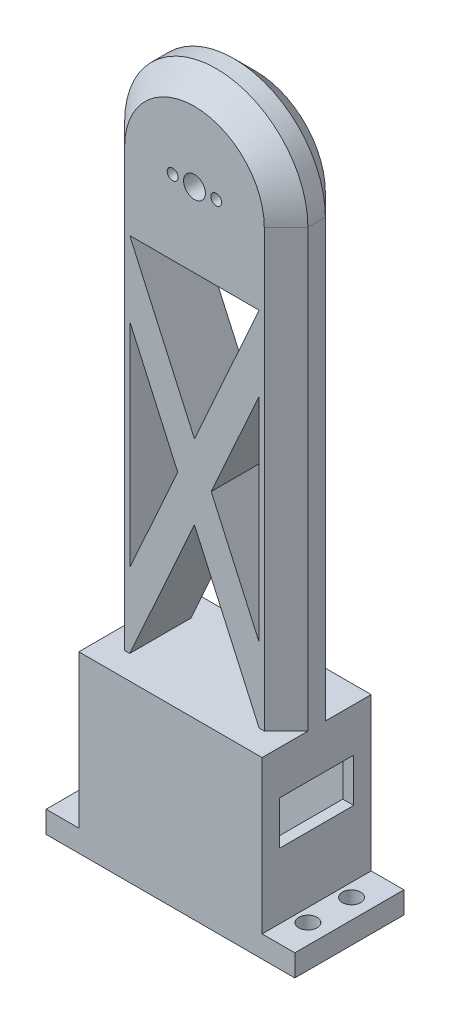
from build123d import *

# Parameters (mm, degrees)
BOSS_EXTRUDE1_DEPTH = 7
SKETCH2_W           = 42
SKETCH2_H           = 25
BOSS_EXTRUDE2_DEPTH = 40
SHELL1_T            = -2.5
CUT_EXTRUDE5_REACH  = 144.903
SKETCH8_R           = 1.25
SKETCH8_R_2         = 2.5
SKETCH9_W           = 10
SKETCH9_H           = 25
BOSS_EXTRUDE3_DEPTH = 5
CUT_EXTRUDE6_REACH  = 151.018
SKETCH10_W          = 17
SKETCH10_H          = 10
CUT_EXTRUDE8_REACH  = 146.196
CUT_EXTRUDE9_REACH  = 165.98
SKETCH13_R          = 2.1
CHAMFER1_SIZE       = 5


with BuildPart() as part:
    # Sketch1 → Boss-Extrude1 (new, symmetric)
    with BuildSketch(Plane.XY):
        with BuildLine():
            Line((-21, 0), (-21, -100))
            Line((-21, -100), (21, -100))
            Line((21, -100), (21, 0))
            ThreePointArc((21, 0), (0, 21), (-21, 0))
        make_face()
    extrude(amount=BOSS_EXTRUDE1_DEPTH, both=True)


with BuildPart() as body_2:
    # Sketch2 → Boss-Extrude2 (new body)
    with BuildSketch(Plane.XZ.offset(100)):
        Rectangle(SKETCH2_W, SKETCH2_H)
    extrude(amount=BOSS_EXTRUDE2_DEPTH)

    # Shell1
    shell1_openings = [body_2.faces().sort_by_distance(p)[0] for p in [
        (0, -140, 0),
    ]]
    offset(amount=SHELL1_T, openings=shell1_openings, kind=Kind.INTERSECTION)


with BuildPart() as part_1:
    add(part.part)

    # Combine1: union body 2
    add(body_2.part)

    # Sketch8 → Cut-Extrude5 (cut, up to next)
    with BuildSketch(Plane.XY.offset(7), mode=Mode.PRIVATE) as cut_extrude5_sk1:
        with Locations((5, 0)):
            Circle(SKETCH8_R)
    cut_extrude5_tool1 = extrude(cut_extrude5_sk1.sketch, amount=-CUT_EXTRUDE5_REACH, mode=Mode.PRIVATE) & part_1.part
    # Sketch8 → Cut-Extrude5 (cut, up to next)
    with BuildSketch(Plane.XY.offset(7), mode=Mode.PRIVATE) as cut_extrude5_sk2:
        Circle(SKETCH8_R_2)
    cut_extrude5_tool2 = extrude(cut_extrude5_sk2.sketch, amount=-CUT_EXTRUDE5_REACH, mode=Mode.PRIVATE) & part_1.part
    # Sketch8 → Cut-Extrude5 (cut, up to next)
    with BuildSketch(Plane.XY.offset(7), mode=Mode.PRIVATE) as cut_extrude5_sk3:
        with Locations((-5, 0)):
            Circle(SKETCH8_R)
    cut_extrude5_tool3 = extrude(cut_extrude5_sk3.sketch, amount=-CUT_EXTRUDE5_REACH, mode=Mode.PRIVATE) & part_1.part
    add(cut_extrude5_tool1.solids().sort_by_distance((5, 0, 7))[0], mode=Mode.SUBTRACT)
    add(cut_extrude5_tool2.solids().sort_by_distance((0, 0, 7))[0], mode=Mode.SUBTRACT)
    add(cut_extrude5_tool3.solids().sort_by_distance((-5, 0, 7))[0], mode=Mode.SUBTRACT)

    # Sketch9 → Boss-Extrude3 (add)
    with BuildSketch(Plane.XZ.offset(140)):
        with Locations((-23.5, 0)):
            Rectangle(SKETCH9_W, SKETCH9_H)
        with Locations((23.5, 0)):
            Rectangle(SKETCH9_W, SKETCH9_H)
    extrude(amount=-BOSS_EXTRUDE3_DEPTH)

    # Sketch10 → Cut-Extrude6 (cut, up to next)
    with BuildSketch(Plane(origin=(21, 0, 0), x_dir=(0, 0, -1), z_dir=(1, 0, 0)), mode=Mode.PRIVATE) as cut_extrude6_sk1:
        with Locations((0, -115)):
            Rectangle(SKETCH10_W, SKETCH10_H)
    cut_extrude6_tool1 = extrude(cut_extrude6_sk1.sketch, amount=-CUT_EXTRUDE6_REACH, mode=Mode.PRIVATE) & part_1.part
    add(cut_extrude6_tool1.solids().sort_by_distance((21, -115, 0))[0], mode=Mode.SUBTRACT)

    # Sketch12 → Cut-Extrude8 (cut, up to next)
    with BuildSketch(Plane.XY.offset(7), mode=Mode.PRIVATE) as cut_extrude8_sk1:
        Polygon((14.82390073, -82.942001623), (14.82390073, -34.115996755), (3.838049635, -58.528999189), align=None)
    cut_extrude8_tool1 = extrude(cut_extrude8_sk1.sketch, amount=-CUT_EXTRUDE8_REACH, mode=Mode.PRIVATE) & part_1.part
    # Sketch12 → Cut-Extrude8 (cut, up to next)
    with BuildSketch(Plane.XY.offset(7), mode=Mode.PRIVATE) as cut_extrude8_sk2:
        Polygon((14.82390073, -17.057998377), (-14.82390073, -17.057998377), (0, -50), align=None)
    cut_extrude8_tool2 = extrude(cut_extrude8_sk2.sketch, amount=-CUT_EXTRUDE8_REACH, mode=Mode.PRIVATE) & part_1.part
    # Sketch12 → Cut-Extrude8 (cut, up to next)
    with BuildSketch(Plane.XY.offset(7), mode=Mode.PRIVATE) as cut_extrude8_sk3:
        Polygon((-3.838049635, -58.528999189), (-14.82390073, -34.115996755), (-14.82390073, -82.942001623), align=None)
    cut_extrude8_tool3 = extrude(cut_extrude8_sk3.sketch, amount=-CUT_EXTRUDE8_REACH, mode=Mode.PRIVATE) & part_1.part
    # Sketch12 → Cut-Extrude8 (cut, up to next)
    with BuildSketch(Plane.XY.offset(7), mode=Mode.PRIVATE) as cut_extrude8_sk4:
        Polygon((14.82390073, -100), (0, -67.057998377), (-14.82390073, -100), align=None)
    cut_extrude8_tool4 = extrude(cut_extrude8_sk4.sketch, amount=-CUT_EXTRUDE8_REACH, mode=Mode.PRIVATE) & part_1.part
    add(cut_extrude8_tool1.solids().sort_by_distance((11.16195, -58.528999, 7))[0], mode=Mode.SUBTRACT)
    add(cut_extrude8_tool2.solids().sort_by_distance((0, -28.038666, 7))[0], mode=Mode.SUBTRACT)
    add(cut_extrude8_tool3.solids().sort_by_distance((-11.16195, -58.528999, 7))[0], mode=Mode.SUBTRACT)
    add(cut_extrude8_tool4.solids().sort_by_distance((0, -89.019333, 7))[0], mode=Mode.SUBTRACT)

    # Sketch13 → Cut-Extrude9 (cut, up to next)
    with BuildSketch(Plane.XZ.offset(140), mode=Mode.PRIVATE) as cut_extrude9_sk1:
        with Locations((24, 5)):
            Circle(SKETCH13_R)
    cut_extrude9_tool1 = extrude(cut_extrude9_sk1.sketch, amount=-CUT_EXTRUDE9_REACH, mode=Mode.PRIVATE) & part_1.part
    # Sketch13 → Cut-Extrude9 (cut, up to next)
    with BuildSketch(Plane.XZ.offset(140), mode=Mode.PRIVATE) as cut_extrude9_sk2:
        with Locations((24, -5)):
            Circle(SKETCH13_R)
    cut_extrude9_tool2 = extrude(cut_extrude9_sk2.sketch, amount=-CUT_EXTRUDE9_REACH, mode=Mode.PRIVATE) & part_1.part
    # Sketch13 → Cut-Extrude9 (cut, up to next)
    with BuildSketch(Plane.XZ.offset(140), mode=Mode.PRIVATE) as cut_extrude9_sk3:
        with Locations((-24, 5)):
            Circle(SKETCH13_R)
    cut_extrude9_tool3 = extrude(cut_extrude9_sk3.sketch, amount=-CUT_EXTRUDE9_REACH, mode=Mode.PRIVATE) & part_1.part
    # Sketch13 → Cut-Extrude9 (cut, up to next)
    with BuildSketch(Plane.XZ.offset(140), mode=Mode.PRIVATE) as cut_extrude9_sk4:
        with Locations((-24, -5)):
            Circle(SKETCH13_R)
    cut_extrude9_tool4 = extrude(cut_extrude9_sk4.sketch, amount=-CUT_EXTRUDE9_REACH, mode=Mode.PRIVATE) & part_1.part
    add(cut_extrude9_tool1.solids().sort_by_distance((24, -140, 5))[0], mode=Mode.SUBTRACT)
    add(cut_extrude9_tool2.solids().sort_by_distance((24, -140, -5))[0], mode=Mode.SUBTRACT)
    add(cut_extrude9_tool3.solids().sort_by_distance((-24, -140, 5))[0], mode=Mode.SUBTRACT)
    add(cut_extrude9_tool4.solids().sort_by_distance((-24, -140, -5))[0], mode=Mode.SUBTRACT)

    # Chamfer1
    chamfer1_edges = [part_1.edges().sort_by_distance(p)[0] for p in [
        (21, -50, 7),
        (-21, -50, 7),
        (0, 21, 7),
        (21, -50, -7),
        (-21, -50, -7),
        (0, 21, -7),
    ]]
    chamfer(chamfer1_edges, length=CHAMFER1_SIZE)


solid = part_1.part
